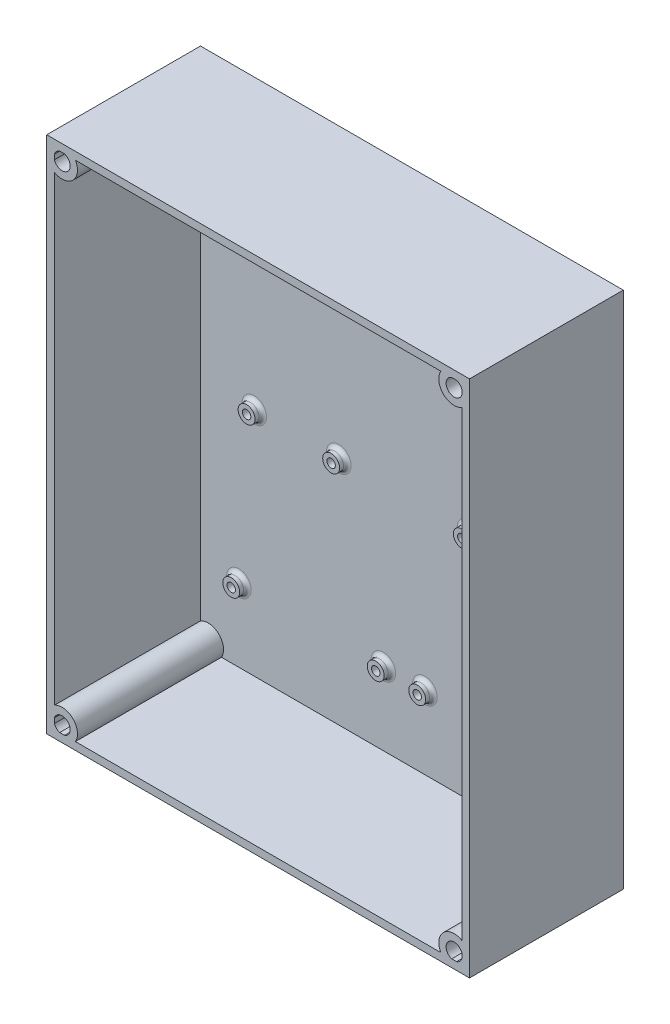
from build123d import *

# Parameters (mm, degrees)
SKETCH1_W           = 139.7
SKETCH1_H           = 171.45
BOSS_EXTRUDE1_DEPTH = 50.8
SHELL2_T            = -2.54
SKETCH3_R           = 5.08
SKETCH3_R_2         = 2.667
BOSS_EXTRUDE3_DEPTH = 50.8
SKETCH4_R           = 2.794
SKETCH4_R_2         = 1.397
BOSS_EXTRUDE4_DEPTH = 2.54
FILLET1_R           = 1.27


with BuildPart() as part:
    # Sketch1 → Boss-Extrude1 (new body)
    with BuildSketch(Plane.XY):
        with Locations((-69.85, 85.725)):
            Rectangle(SKETCH1_W, SKETCH1_H)
    extrude(amount=BOSS_EXTRUDE1_DEPTH)

    # Shell2
    shell2_openings = [part.faces().sort_by_distance(p)[0] for p in [
        (-69.85, 85.725, 50.8),
    ]]
    offset(amount=SHELL2_T, openings=shell2_openings, kind=Kind.INTERSECTION)

    # Sketch3 → Boss-Extrude3 (add)
    with BuildSketch(Plane.XY.offset(50.8)):
        with Locations((-134.62, 5.08)):
            Circle(SKETCH3_R)
        with Locations((-134.62, 5.08)):
            Circle(SKETCH3_R_2, mode=Mode.SUBTRACT)
        with Locations((-134.62, 166.37)):
            Circle(SKETCH3_R)
        with Locations((-134.62, 166.37)):
            Circle(SKETCH3_R_2, mode=Mode.SUBTRACT)
        with Locations((-5.08, 166.37)):
            Circle(SKETCH3_R)
        with Locations((-5.08, 166.37)):
            Circle(SKETCH3_R_2, mode=Mode.SUBTRACT)
        with Locations((-5.08, 5.08)):
            Circle(SKETCH3_R)
        with Locations((-5.08, 5.08)):
            Circle(SKETCH3_R_2, mode=Mode.SUBTRACT)
    extrude(amount=-BOSS_EXTRUDE3_DEPTH)

    # Sketch4 → Boss-Extrude4 (add)
    with BuildSketch(Plane.XY.offset(2.54)):
        with Locations((-62.992, 26.67)):
            Circle(SKETCH4_R)
        with Locations((-62.992, 26.67)):
            Circle(SKETCH4_R_2, mode=Mode.SUBTRACT)
        with Locations((-48.26, 78.74)):
            Circle(SKETCH4_R)
        with Locations((-48.26, 78.74)):
            Circle(SKETCH4_R_2, mode=Mode.SUBTRACT)
        with Locations((-20.32, 78.74)):
            Circle(SKETCH4_R)
        with Locations((-20.32, 78.74)):
            Circle(SKETCH4_R_2, mode=Mode.SUBTRACT)
        with Locations((-15.24, 26.67)):
            Circle(SKETCH4_R)
        with Locations((-15.24, 26.67)):
            Circle(SKETCH4_R_2, mode=Mode.SUBTRACT)
        with Locations((-76.708, 26.67)):
            Circle(SKETCH4_R)
        with Locations((-76.708, 26.67)):
            Circle(SKETCH4_R_2, mode=Mode.SUBTRACT)
        with Locations((-91.44, 78.74)):
            Circle(SKETCH4_R)
        with Locations((-91.44, 78.74)):
            Circle(SKETCH4_R_2, mode=Mode.SUBTRACT)
        with Locations((-119.38, 78.74)):
            Circle(SKETCH4_R)
        with Locations((-119.38, 78.74)):
            Circle(SKETCH4_R_2, mode=Mode.SUBTRACT)
        with Locations((-124.46, 26.67)):
            Circle(SKETCH4_R)
        with Locations((-124.46, 26.67)):
            Circle(SKETCH4_R_2, mode=Mode.SUBTRACT)
    extrude(amount=BOSS_EXTRUDE4_DEPTH)

    # Fillet1
    fillet1_edges = [part.edges().sort_by_distance(p)[0] for p in [
        (-65.786, 26.67, 2.54),
        (-51.054, 78.74, 2.54),
        (-23.114, 78.74, 2.54),
        (-18.034, 26.67, 2.54),
        (-79.502, 26.67, 2.54),
        (-94.234, 78.74, 2.54),
        (-122.174, 78.74, 2.54),
        (-127.254, 26.67, 2.54),
    ]]
    fillet(fillet1_edges, radius=FILLET1_R)


solid = part.part
